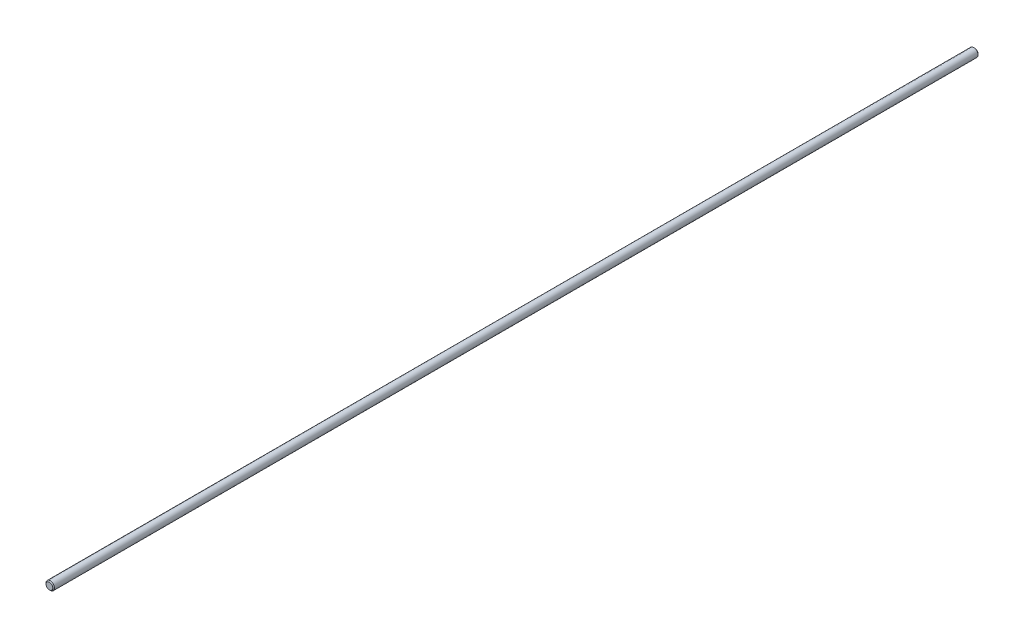
from build123d import *

# Parameters (mm, degrees)
SKETCH1_R           = 5
BOSS_EXTRUDE1_DEPTH = 1093
CHAMFER1_SIZE       = 1


with BuildPart() as part:
    # Sketch1 → Boss-Extrude1 (new body)
    with BuildSketch(Plane.XY):
        Circle(SKETCH1_R)
    extrude(amount=BOSS_EXTRUDE1_DEPTH)

    # Chamfer1
    chamfer1_edges = [part.edges().sort_by_distance(p)[0] for p in [
        (-5, 0, 0),
        (-5, 0, 1093),
    ]]
    chamfer(chamfer1_edges, length=CHAMFER1_SIZE)


solid = part.part
